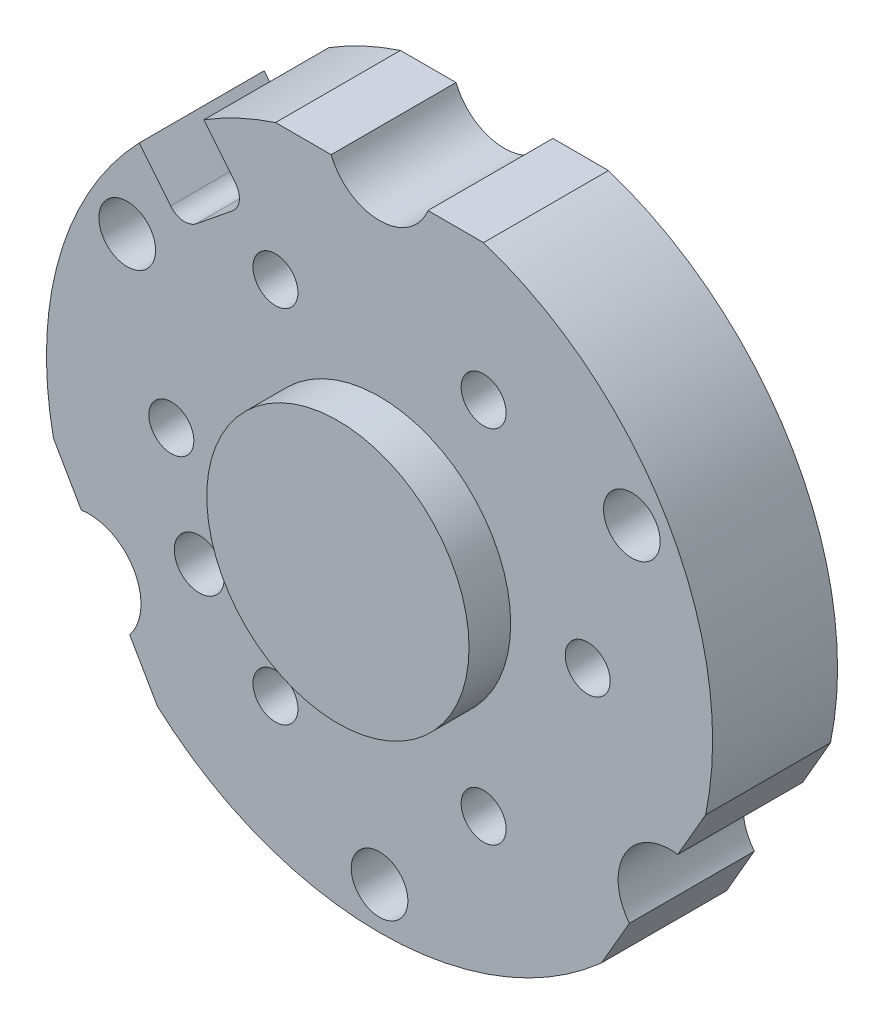
from build123d import *

# Parameters (mm, degrees)
ESTRUSIONE_ESTRUSIONE1_DEPTH = 15
ESTRUSIONE_ESTRUSIONE5_DEPTH = 0.3
TAGLIO_ESTRUSIONE1_DEPTH     = 16.3
TAGLIO_ESTRUSIONE2_DEPTH     = 16
ESTRUSIONE_ESTRUSIONE2_DEPTH = 5
SCHIZZO7_R                   = 6
TAGLIO_ESTRUSIONE3_DEPTH     = 7


with BuildPart() as part:
    # Schizzo1 → Estrusione-Estrusione1 (new body)
    with BuildSketch(Plane.XY):
        with BuildLine():
            Line((-5.811411188, 38), (-12.489995997, 38))
            ThreePointArc((-12.489995997, 38), (-16.909196271, 36.250228709), (-21.089648938, 33.988626151))
            Line((-21.089648938, 33.988626151), (-17.322367371, 29.336420856))
            ThreePointArc((-17.322367371, 29.336420856), (-16.844140316, 27.721953377), (-17.647583626, 26.242194881))
            Line((-17.647583626, 26.242194881), (-21.99960101, 22.718000691))
            ThreePointArc((-21.99960101, 22.718000691), (-23.61406849, 22.239773636), (-25.093826986, 23.043216946))
            Line((-25.093826986, 23.043216946), (-28.861108553, 27.695422241))
            ThreePointArc((-28.861108553, 27.695422241), (-38.449109313, 11.03023087), (-39.153963342, -8.183346174))
            Line((-39.153963342, -8.183346174), (-35.814606143, -13.967282507))
            ThreePointArc((-35.814606143, -13.967282507), (-29.487341226, -17.025), (-30.002912658, -24.033430901))
            Line((-30.002912658, -24.033430901), (-26.663967345, -29.816653826))
            ThreePointArc((-26.663967345, -29.816653826), (0, -40), (26.663967345, -29.816653826))
            Line((26.663967345, -29.816653826), (30.002912658, -24.033430901))
            ThreePointArc((30.002912658, -24.033430901), (29.487341226, -17.025), (35.814606143, -13.967282507))
            Line((35.814606143, -13.967282507), (39.153963342, -8.183346174))
            ThreePointArc((39.153963342, -8.183346174), (34.641016151, 20), (12.489995997, 38))
            Line((12.489995997, 38), (5.811411188, 38))
            ThreePointArc((5.811411188, 38), (0, 34.05), (-5.811411188, 38))
        make_face()
    extrude(amount=ESTRUSIONE_ESTRUSIONE1_DEPTH)

    # Schizzo5 → Estrusione-Estrusione5 (add)
    with BuildSketch(Plane(origin=(0, 0, 0), x_dir=(-1, 0, 0), z_dir=(0, 0, -1))):
        with BuildLine():
            ThreePointArc((0, -27.5), (27.5, 0), (0, 27.5))
            ThreePointArc((0, 27.5), (-27.5, 0), (0, -27.5))
        make_face()
    extrude(amount=ESTRUSIONE_ESTRUSIONE5_DEPTH)

    # Schizzo2 → Taglio-Estrusione1 (cut, through all)
    with BuildSketch(Plane.XY.offset(15)):
        with BuildLine():
            ThreePointArc((-23.150635095, -9.901923789), (-24.248711306, -14), (-20.150635095, -15.098076211))
            ThreePointArc((-20.150635095, -15.098076211), (-19.052558883, -11), (-23.150635095, -9.901923789))
        make_face()
        with BuildLine():
            ThreePointArc((-11.15, 19.312366504), (-10.16173141, 23.000635095), (-13.85, 23.988903685))
            ThreePointArc((-13.85, 23.988903685), (-14.83826859, 20.300635095), (-11.15, 19.312366504))
        make_face()
        with BuildLine():
            ThreePointArc((11.15, 23.988903685), (10.16173141, 20.300635095), (13.85, 19.312366504))
            ThreePointArc((13.85, 19.312366504), (14.83826859, 23.000635095), (11.15, 23.988903685))
        make_face()
        with BuildLine():
            ThreePointArc((26.35, -2.33826859), (27.33826859, 1.35), (23.65, 2.33826859))
            ThreePointArc((23.65, 2.33826859), (22.66173141, -1.35), (26.35, -2.33826859))
        make_face()
        with BuildLine():
            ThreePointArc((13.85, -23.988903685), (14.83826859, -20.300635095), (11.15, -19.312366504))
            ThreePointArc((11.15, -19.312366504), (10.16173141, -23.000635095), (13.85, -23.988903685))
        make_face()
        with BuildLine():
            ThreePointArc((-11.15, -23.988903685), (-10.16173141, -20.300635095), (-13.85, -19.312366504))
            ThreePointArc((-13.85, -19.312366504), (-14.83826859, -23.000635095), (-11.15, -23.988903685))
        make_face()
        with BuildLine():
            ThreePointArc((-23.65, -2.33826859), (-22.66173141, 1.35), (-26.35, 2.33826859))
            ThreePointArc((-26.35, 2.33826859), (-27.33826859, -1.35), (-23.65, -2.33826859))
        make_face()
    extrude(amount=-TAGLIO_ESTRUSIONE1_DEPTH, mode=Mode.SUBTRACT)

    # Schizzo3 → Taglio-Estrusione2 (cut, through all)
    with BuildSketch(Plane(origin=(0, 0, 0), x_dir=(-1, 0, 0), z_dir=(0, 0, -1))):
        with BuildLine():
            ThreePointArc((30.3, 20.9), (26.9, 17.5), (30.3, 14.1))
            ThreePointArc((30.3, 14.1), (33.7, 17.5), (30.3, 20.9))
        make_face()
        with BuildLine():
            ThreePointArc((0, -38.4), (3.4, -35), (0, -31.6))
            ThreePointArc((0, -31.6), (-3.4, -35), (0, -38.4))
        make_face()
        with BuildLine():
            ThreePointArc((-30.3, 20.9), (-33.7, 17.5), (-30.3, 14.1))
            ThreePointArc((-30.3, 14.1), (-26.9, 17.5), (-30.3, 20.9))
        make_face()
    extrude(amount=-TAGLIO_ESTRUSIONE2_DEPTH, mode=Mode.SUBTRACT)

    # Schizzo4 → Estrusione-Estrusione2 (add)
    with BuildSketch(Plane.XY.offset(15)):
        with BuildLine():
            ThreePointArc((-7.875, 13.63990011), (-13.63990011, -7.875), (7.875, -13.63990011))
            ThreePointArc((7.875, -13.63990011), (13.63990011, 7.875), (-7.875, 13.63990011))
        make_face()
    extrude(amount=ESTRUSIONE_ESTRUSIONE2_DEPTH)

    # Schizzo7 → Taglio-Estrusione3 (cut)
    with BuildSketch(Plane(origin=(0, 0, -0.3), x_dir=(-1, 0, 0), z_dir=(0, 0, -1))):
        with Locations((-12.5, 21.650635095)):
            Circle(SCHIZZO7_R)
        with Locations((12.5, 21.650635095)):
            Circle(SCHIZZO7_R)
        with Locations((25, 0)):
            Circle(SCHIZZO7_R)
        with Locations((12.5, -21.650635095)):
            Circle(SCHIZZO7_R)
        with Locations((-12.5, -21.650635095)):
            Circle(SCHIZZO7_R)
        with Locations((-25, 0)):
            Circle(SCHIZZO7_R)
    extrude(amount=-TAGLIO_ESTRUSIONE3_DEPTH, mode=Mode.SUBTRACT)


solid = part.part
